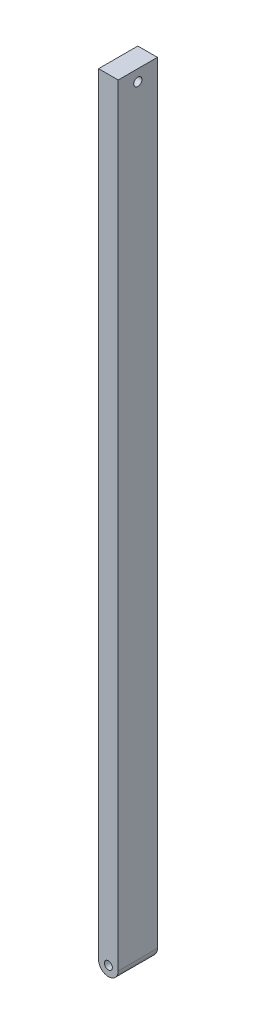
from build123d import *

# Parameters (mm, degrees)
SKETCH5_R           = 0.203870929
BOSS_EXTRUDE2_DEPTH = 2
SKETCH7_R           = 0.208826812
CUT_EXTRUDE5_DEPTH  = 2


with BuildPart() as part:
    # Sketch5 → Boss-Extrude2 (new body)
    with BuildSketch(Plane.XY):
        with BuildLine():
            Line((-1, -2.147995304), (-1, -40.897995304))
            ThreePointArc((-1, -40.897995304), (-0.5, -41.397995304), (0, -40.897995304))
            Line((0, -40.897995304), (0, -2.147995304))
            Line((0, -2.147995304), (0, -1.567995304))
            Line((0, -1.567995304), (-1, -1.567995304))
            Line((-1, -1.567995304), (-1, -2.147995304))
        make_face()
        with Locations((-0.5, -40.897995304)):
            Circle(SKETCH5_R, mode=Mode.SUBTRACT)
    extrude(amount=BOSS_EXTRUDE2_DEPTH)

    # Sketch7 → Cut-Extrude5 (cut, through all)
    with BuildSketch(Plane(origin=(0, 0, 0), x_dir=(0, 0, -1), z_dir=(1, 0, 0))):
        with Locations((-1, -2.147995304)):
            Circle(SKETCH7_R)
    extrude(amount=-CUT_EXTRUDE5_DEPTH, mode=Mode.SUBTRACT)


solid = part.part
